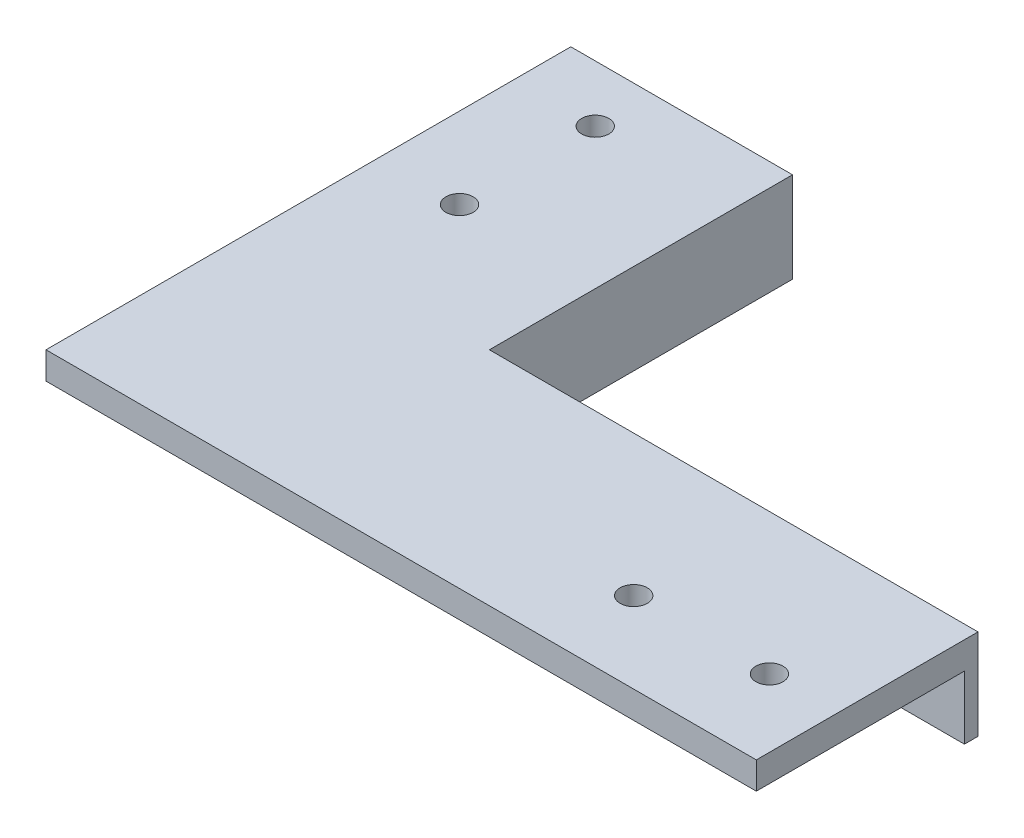
from build123d import *

# Parameters (mm, degrees)
SALIENTE_EXTRUIR1_DEPTH = 3
CROQUIS2_R              = 1.5
CORTAR_EXTRUIR2_DEPTH   = 4
SALIENTE_EXTRUIR2_DEPTH = 10


with BuildPart() as part:
    # Croquis1 → Saliente-Extruir1 (new body)
    with BuildSketch(Plane(origin=(0, 0, 0), x_dir=(1, 0, 0), z_dir=(0, 1, 0))):
        Polygon((-16.25, 29), (-16.25, -6), (39.25, -6), (39.25, -29), (-39.25, -29), (-39.25, 29), align=None)
    extrude(amount=SALIENTE_EXTRUIR1_DEPTH)

    # Croquis2 → Cortar-Extruir2 (cut, through all)
    with BuildSketch(Plane(origin=(0, 3, 0), x_dir=(1, 0, 0), z_dir=(0, 1, 0))):
        with Locations((31.75, -20.05)):
            Circle(CROQUIS2_R)
        with Locations((16.75, -20.05)):
            Circle(CROQUIS2_R)
        with Locations((-30.3, 22.75)):
            Circle(CROQUIS2_R)
        with Locations((-30.3, 7.75)):
            Circle(CROQUIS2_R)
    extrude(amount=-CORTAR_EXTRUIR2_DEPTH, mode=Mode.SUBTRACT)

    # Croquis3 → Saliente-Extruir2 (add)
    with BuildSketch(Plane(origin=(0, 3, 0), x_dir=(1, 0, 0), z_dir=(0, 1, 0))):
        Polygon((-16.25, 29), (-16.25, -6), (39.25, -6), (39.25, -4.5), (-14.75, -4.5), (-14.75, 29), align=None)
    extrude(amount=-SALIENTE_EXTRUIR2_DEPTH)


solid = part.part
